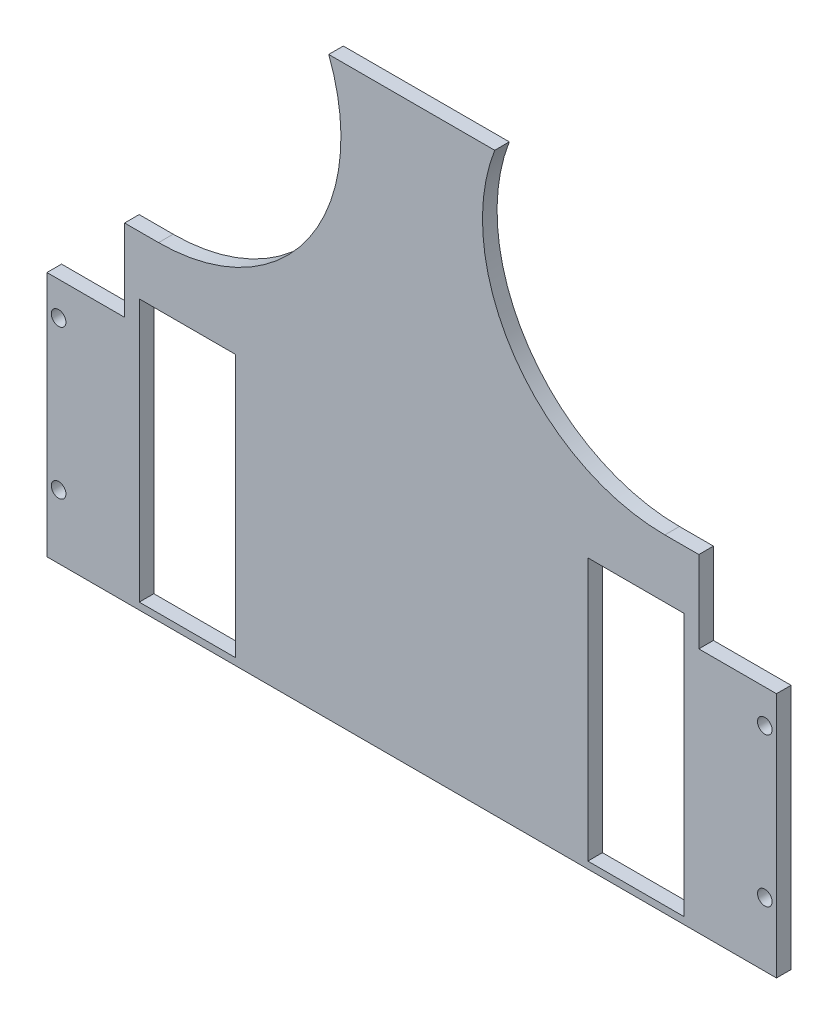
from build123d import *

# Parameters (mm, degrees)
SKETCH1_W           = 250
SKETCH1_H           = 267.4
SKETCH1_R           = 2.5
SKETCH1_W_2         = 33
SKETCH1_H_2         = 90
BOSS_EXTRUDE1_DEPTH = 5
SKETCH6_W           = 250
SKETCH6_H           = 70.024397165
CUT_EXTRUDE4_DEPTH  = 6


with BuildPart() as part:
    # Sketch1 → Boss-Extrude1 (new body)
    with BuildSketch(Plane.XY):
        with Locations((-3272.432417868, -202.7)):
            Rectangle(SKETCH1_W, SKETCH1_H)
        with Locations((-3151.432417868, -193.5)):
            Circle(SKETCH1_R, mode=Mode.SUBTRACT)
        with Locations((-3151.432417868, -244.5)):
            Circle(SKETCH1_R, mode=Mode.SUBTRACT)
        with Locations((-3393.432417868, -244.5)):
            Circle(SKETCH1_R, mode=Mode.SUBTRACT)
        with Locations((-3393.432417868, -193.5)):
            Circle(SKETCH1_R, mode=Mode.SUBTRACT)
        with Locations((-3195.572417868, -219)):
            Rectangle(SKETCH1_W_2, SKETCH1_H_2, mode=Mode.SUBTRACT)
        with Locations((-3349.292417868, -219)):
            Rectangle(SKETCH1_W_2, SKETCH1_H_2, mode=Mode.SUBTRACT)
    extrude(amount=BOSS_EXTRUDE1_DEPTH)

    # Sketch6 → Cut-Extrude4 (cut, through all)
    with BuildSketch(Plane.XY.offset(5)):
        with BuildLine():
            Line((-3243.992329325, -69), (-3147.432417868, -69))
            Line((-3147.432417868, -69), (-3147.432417868, -182))
            Line((-3147.432417868, -182), (-3174.036756226, -182))
            Line((-3174.036756226, -182), (-3174.036756226, -154))
            Line((-3174.036756226, -154), (-3185.682810376, -154))
            ThreePointArc((-3185.682810376, -154), (-3237.221630697, -126.855339059), (-3243.992329325, -69))
        make_face()
        with Locations((-3272.432417868, -301.387801417)):
            Rectangle(SKETCH6_W, SKETCH6_H)
        with BuildLine():
            Line((-3300.872506412, -69), (-3397.432417868, -69))
            Line((-3397.432417868, -69), (-3397.432417868, -182))
            Line((-3397.432417868, -182), (-3370.82807951, -182))
            Line((-3370.82807951, -182), (-3370.82807951, -154))
            Line((-3370.82807951, -154), (-3359.18202536, -154))
            ThreePointArc((-3359.18202536, -154), (-3307.64320504, -126.855339059), (-3300.872506412, -69))
        make_face()
    extrude(amount=-CUT_EXTRUDE4_DEPTH, mode=Mode.SUBTRACT)


solid = part.part
